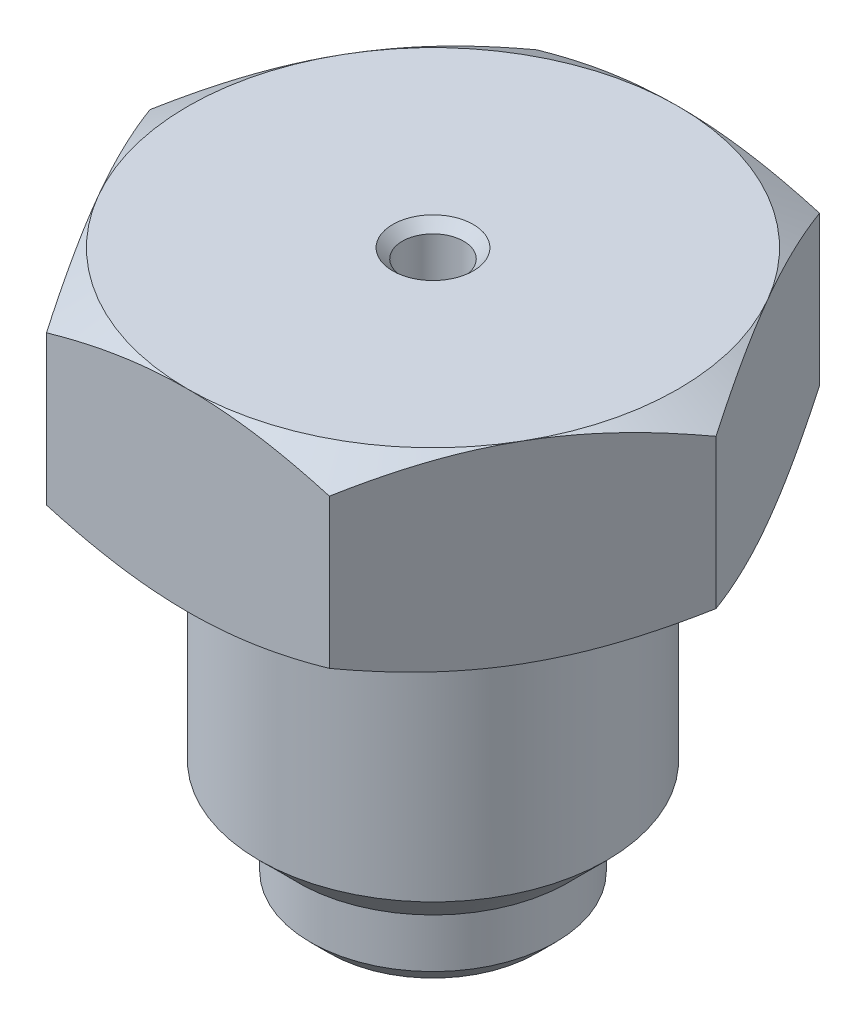
from build123d import *

# Parameters (mm, degrees)
SALIENTE_EXTRUIR3_DEPTH = 10
CROQUIS5_OUTSIDE_W      = 73.984
CROQUIS5_OUTSIDE_H      = 70.054
CROQUIS5_OUTSIDE_R      = 12.7
CORTAR_EXTRUIR4_DEPTH   = 10
CORTAR_EXTRUIR4_TAPER   = 60
CROQUIS6_OUTSIDE_W      = 73.984
CROQUIS6_OUTSIDE_H      = 70.054
CROQUIS6_OUTSIDE_R      = 12.7
CORTAR_EXTRUIR5_DEPTH   = 10
CORTAR_EXTRUIR5_TAPER   = 60
CROQUIS7_R              = 9
SALIENTE_EXTRUIR4_DEPTH = 15
CHAFL_N1_SIZE           = 2
CROQUIS8_R              = 1.5875
CORTAR_EXTRUIR6_DEPTH   = 26
CHAFL_N2_SIZE           = 0.5
CROQUIS9_R              = 6.35
SALIENTE_EXTRUIR5_DEPTH = 4
CHAFL_N4_SIZE           = 1
CROQUIS10_R             = 1.5875
CORTAR_EXTRUIR7_DEPTH   = 14


with BuildPart() as part:
    # Croquis1 → Saliente-Extruir3 (new body)
    with BuildSketch(Plane(origin=(0, 0, 0), x_dir=(1, 0, 0), z_dir=(0, 1, 0))):
        Polygon((14.664696837, 0), (7.332348419, 12.7), (-7.332348419, 12.7), (-14.664696837, 0), (-7.332348419, -12.7), (7.332348419, -12.7), align=None)
    extrude(amount=SALIENTE_EXTRUIR3_DEPTH)

    # Croquis5 outside → Cortar-Extruir4 (cut)
    with BuildSketch(Plane.XZ):
        Rectangle(CROQUIS5_OUTSIDE_W, CROQUIS5_OUTSIDE_H)
        Circle(CROQUIS5_OUTSIDE_R, mode=Mode.SUBTRACT)
    extrude(amount=-CORTAR_EXTRUIR4_DEPTH, taper=CORTAR_EXTRUIR4_TAPER, mode=Mode.SUBTRACT)

    # Croquis6 outside → Cortar-Extruir5 (cut)
    with BuildSketch(Plane(origin=(0, 10, 0), x_dir=(1, 0, 0), z_dir=(0, 1, 0))):
        Rectangle(CROQUIS6_OUTSIDE_W, CROQUIS6_OUTSIDE_H)
        Circle(CROQUIS6_OUTSIDE_R, mode=Mode.SUBTRACT)
    extrude(amount=-CORTAR_EXTRUIR5_DEPTH, taper=CORTAR_EXTRUIR5_TAPER, mode=Mode.SUBTRACT)

    # Croquis7 → Saliente-Extruir4 (add)
    with BuildSketch(Plane.XZ):
        Circle(CROQUIS7_R)
    extrude(amount=SALIENTE_EXTRUIR4_DEPTH)

    # Chaflán1
    chafl_n1_edges = [part.edges().sort_by_distance(p)[0] for p in [
        (-9, -15, 0),
    ]]
    chamfer(chafl_n1_edges, length=CHAFL_N1_SIZE)

    # Croquis8 → Cortar-Extruir6 (cut)
    with BuildSketch(Plane(origin=(0, 10, 0), x_dir=(1, 0, 0), z_dir=(0, 1, 0))):
        Circle(CROQUIS8_R)
    extrude(amount=-CORTAR_EXTRUIR6_DEPTH, mode=Mode.SUBTRACT)

    # Chaflán2
    chafl_n2_edges = [part.edges().sort_by_distance(p)[0] for p in [
        (-1.5875, 10, 0),
    ]]
    chamfer(chafl_n2_edges, length=CHAFL_N2_SIZE)

    # Croquis9 → Saliente-Extruir5 (add)
    with BuildSketch(Plane.XZ.offset(15)):
        Circle(CROQUIS9_R)
    extrude(amount=SALIENTE_EXTRUIR5_DEPTH)

    # Chaflán4
    chafl_n4_edges = [part.edges().sort_by_distance(p)[0] for p in [
        (-6.35, -19, 0),
    ]]
    chamfer(chafl_n4_edges, length=CHAFL_N4_SIZE)

    # Croquis10 → Cortar-Extruir7 (cut)
    with BuildSketch(Plane.XZ.offset(19)):
        Circle(CROQUIS10_R)
    extrude(amount=-CORTAR_EXTRUIR7_DEPTH, mode=Mode.SUBTRACT)


solid = part.part
